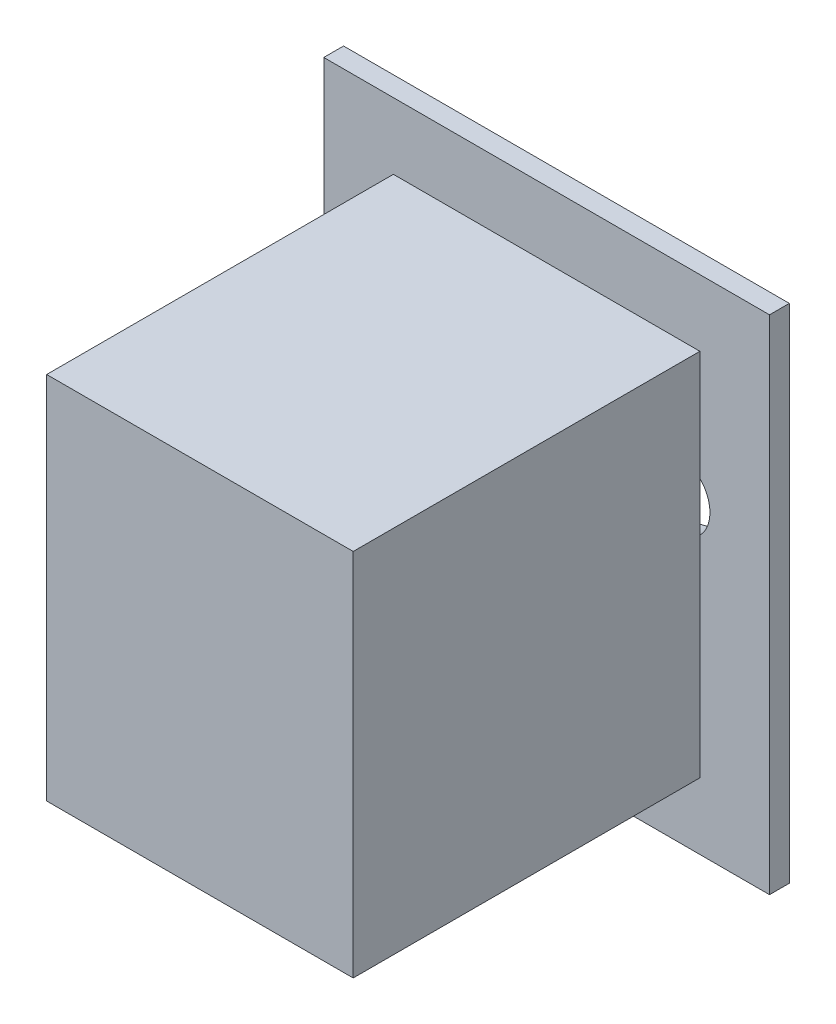
from build123d import *

# Parameters (mm, degrees)
SKETCH1_W           = 45
SKETCH1_H           = 50.7
SKETCH1_R           = 2.636973336
SKETCH1_R_2         = 3.554118364
SKETCH1_R_3         = 2.989089767
BOSS_EXTRUDE1_DEPTH = 2
SKETCH2_W           = 30.94366189
SKETCH2_H           = 37.292040818
BOSS_EXTRUDE2_DEPTH = 35


with BuildPart() as part:
    # Sketch1 → Boss-Extrude1 (new body)
    with BuildSketch(Plane.XY):
        Rectangle(SKETCH1_W, SKETCH1_H)
        with Locations((0, 15.621214427)):
            Circle(SKETCH1_R, mode=Mode.SUBTRACT)
        with Locations((-12.932898819, 5.05104632)):
            Circle(SKETCH1_R_2, mode=Mode.SUBTRACT)
        with Locations((-9.047478573, -11.600754735)):
            Circle(SKETCH1_R_3, mode=Mode.SUBTRACT)
        with Locations((9.047478573, -11.600754735)):
            Circle(SKETCH1_R_3, mode=Mode.SUBTRACT)
        with Locations((12.932898819, 5.05104632)):
            Circle(SKETCH1_R_2, mode=Mode.SUBTRACT)
    extrude(amount=BOSS_EXTRUDE1_DEPTH)

    # Sketch2 → Boss-Extrude2 (add)
    with BuildSketch(Plane.XY.offset(2)):
        Rectangle(SKETCH2_W, SKETCH2_H)
    extrude(amount=BOSS_EXTRUDE2_DEPTH)


solid = part.part
